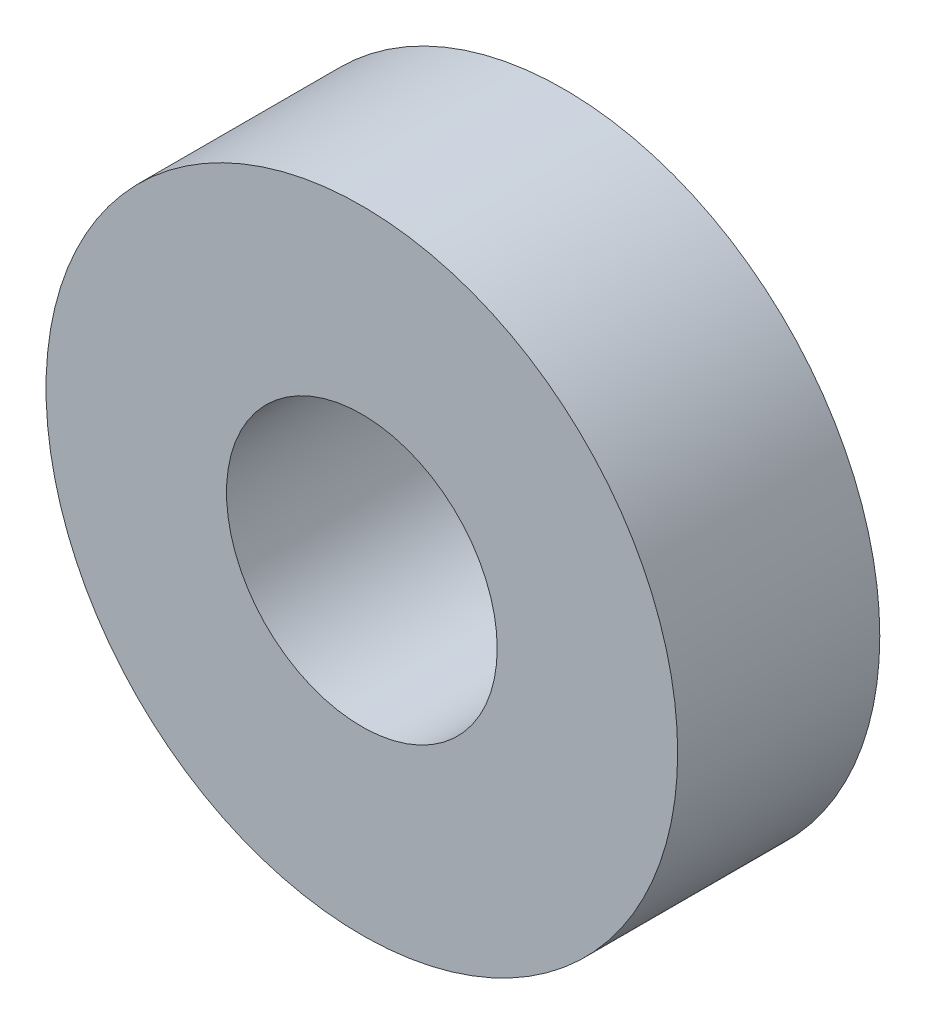
from build123d import *

# Parameters (mm, degrees)
SKETCH1_R           = 11.1125
SKETCH1_R_2         = 4.7625
BOSS_EXTRUDE1_DEPTH = 7.112


with BuildPart() as part:
    # Sketch1 → Boss-Extrude1 (new body)
    with BuildSketch(Plane.XY):
        Circle(SKETCH1_R)
        Circle(SKETCH1_R_2, mode=Mode.SUBTRACT)
    extrude(amount=BOSS_EXTRUDE1_DEPTH)


solid = part.part
